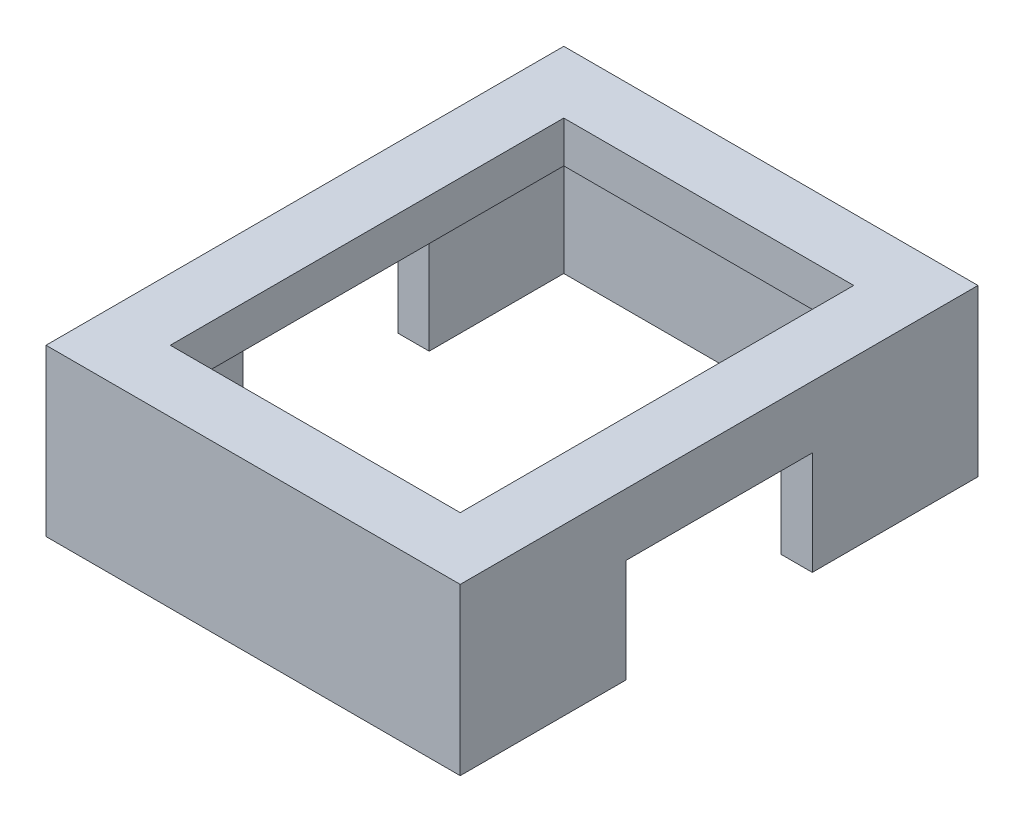
from build123d import *

# Parameters (mm, degrees)
SKETCH1_W           = 20
SKETCH1_H           = 25
BOSS_EXTRUDE1_DEPTH = 8
SKETCH2_W           = 9
SKETCH2_H           = 5
CUT_EXTRUDE1_DEPTH  = 31
SKETCH3_W           = 17
SKETCH3_H           = 22
CUT_EXTRUDE2_DEPTH  = 6
SKETCH4_W           = 14
SKETCH4_H           = 19
CUT_EXTRUDE3_DEPTH  = 7


with BuildPart() as part:
    # Sketch1 → Boss-Extrude1 (new body)
    with BuildSketch(Plane(origin=(0, 0, 0), x_dir=(1, 0, 0), z_dir=(0, 1, 0))):
        with Locations((-10.903225806, -2.629032258)):
            Rectangle(SKETCH1_W, SKETCH1_H)
    extrude(amount=BOSS_EXTRUDE1_DEPTH)

    # Sketch2 → Cut-Extrude1 (cut)
    with BuildSketch(Plane.ZY.offset(20.903225806)):
        with Locations((2.629032258, 2.5)):
            Rectangle(SKETCH2_W, SKETCH2_H)
    extrude(amount=-CUT_EXTRUDE1_DEPTH, mode=Mode.SUBTRACT)

    # Sketch3 → Cut-Extrude2 (cut)
    with BuildSketch(Plane.XZ):
        with Locations((-10.903225806, 2.629032258)):
            Rectangle(SKETCH3_W, SKETCH3_H)
    extrude(amount=-CUT_EXTRUDE2_DEPTH, mode=Mode.SUBTRACT)

    # Sketch4 → Cut-Extrude3 (cut)
    with BuildSketch(Plane(origin=(0, 8, 0), x_dir=(1, 0, 0), z_dir=(0, 1, 0))):
        with Locations((-10.903225806, -2.629032258)):
            Rectangle(SKETCH4_W, SKETCH4_H)
    extrude(amount=-CUT_EXTRUDE3_DEPTH, mode=Mode.SUBTRACT)


solid = part.part
